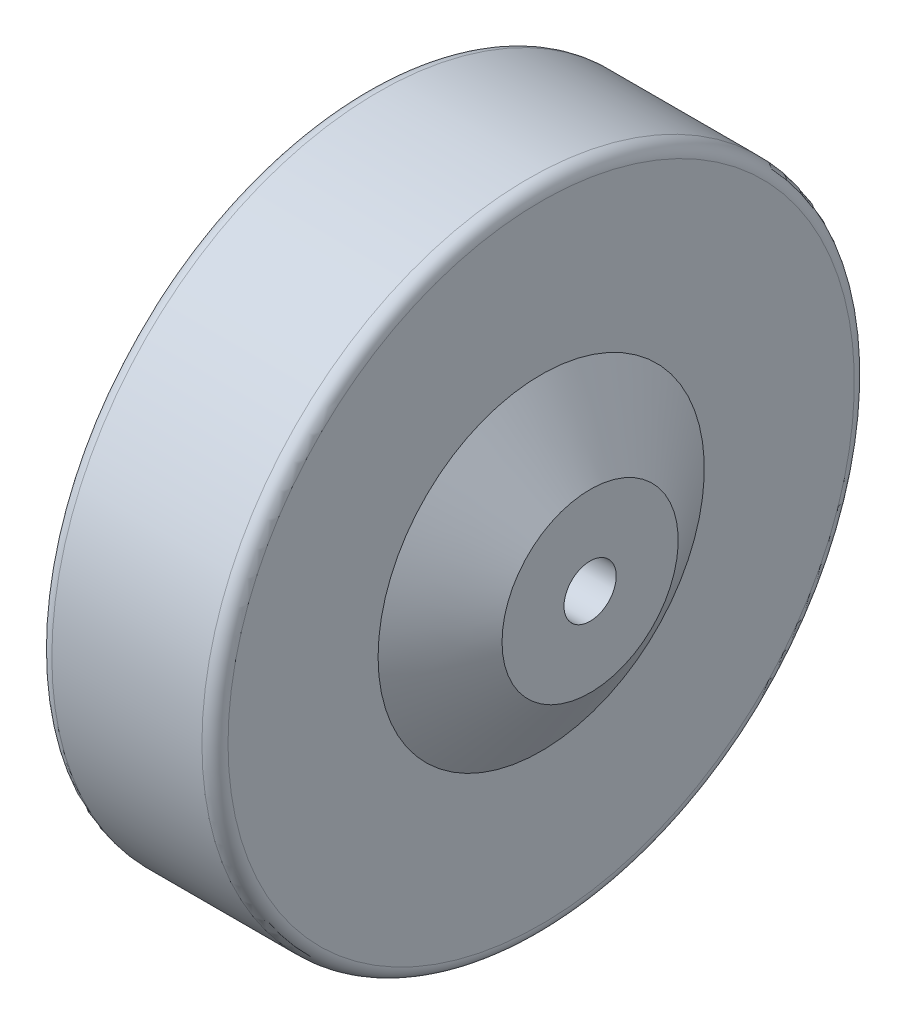
from build123d import *


with BuildPart() as part:
    # Эскиз1 → Повернуть1 (revolve)
    with BuildSketch(Plane.XY):
        with BuildLine():
            Line((21, 4), (-21, 4))
            Line((-21, 4), (-21, 13.5))
            Line((-21, 13.5), (-13.5, 25))
            Line((-13.5, 25), (-13.5, 48))
            ThreePointArc((-13.5, 48), (-12.914213562, 49.414213562), (-11.5, 50))
            Line((-11.5, 50), (11.5, 50))
            ThreePointArc((11.5, 50), (12.914213562, 49.414213562), (13.5, 48))
            Line((13.5, 48), (13.5, 25))
            Line((13.5, 25), (21, 13.5))
            Line((21, 13.5), (21, 4))
        make_face()
    revolve(axis=Axis((-557.663253442, 0, 0), (1, 0, 0)))


solid = part.part
